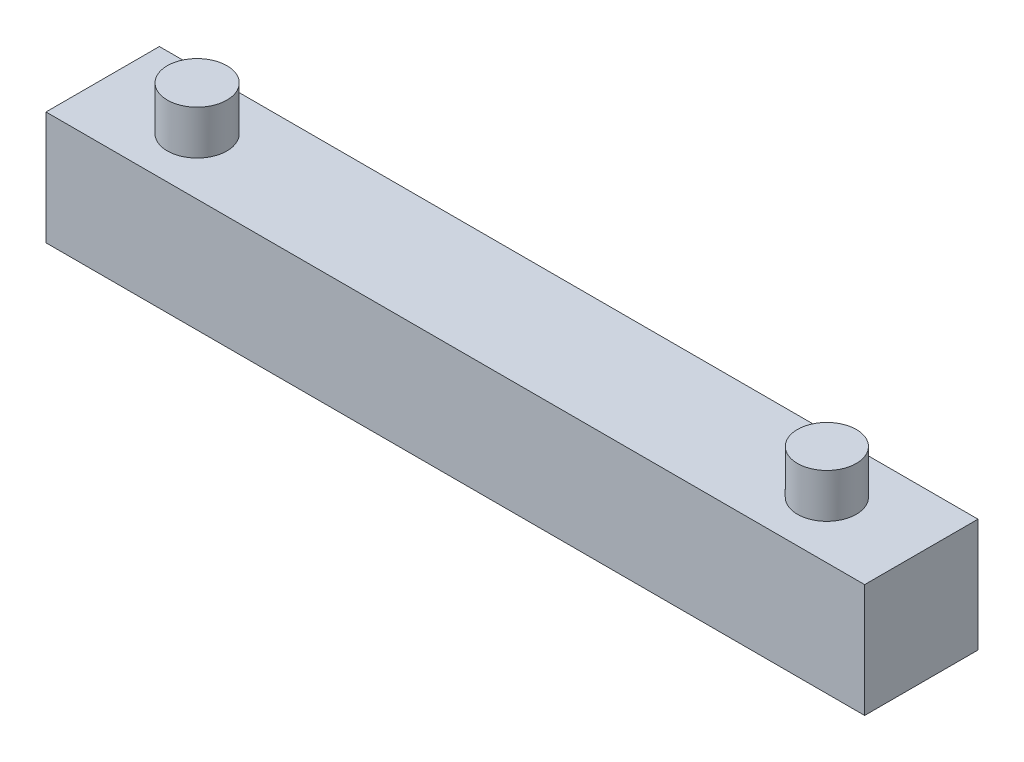
from build123d import *

# Parameters (mm, degrees)
SKETCH2_W           = 65
SKETCH2_H           = 9
BOSS_EXTRUDE1_DEPTH = 9
SKETCH3_R           = 2.366481758
SKETCH3_R_2         = 2.337304334
BOSS_EXTRUDE2_DEPTH = 3.5


with BuildPart() as part:
    # Sketch2 → Boss-Extrude1 (new body)
    with BuildSketch(Plane(origin=(0, 0, 0), x_dir=(1, 0, 0), z_dir=(0, 1, 0))):
        with Locations((32.5, 4.5)):
            Rectangle(SKETCH2_W, SKETCH2_H)
    extrude(amount=BOSS_EXTRUDE1_DEPTH)

    # Sketch3 → Boss-Extrude2 (add)
    with BuildSketch(Plane(origin=(0, 9, 0), x_dir=(1, 0, 0), z_dir=(0, 1, 0))):
        with Locations(Location((7.5, 4.5, 0), (0, 0, 90))):  # turned: the seam where the file's is
            Circle(SKETCH3_R)
        with Locations(Location((57.5, 4.5, 0), (0, 0, 90))):  # turned: the seam where the file's is
            Circle(SKETCH3_R_2)
    extrude(amount=BOSS_EXTRUDE2_DEPTH)


solid = part.part
